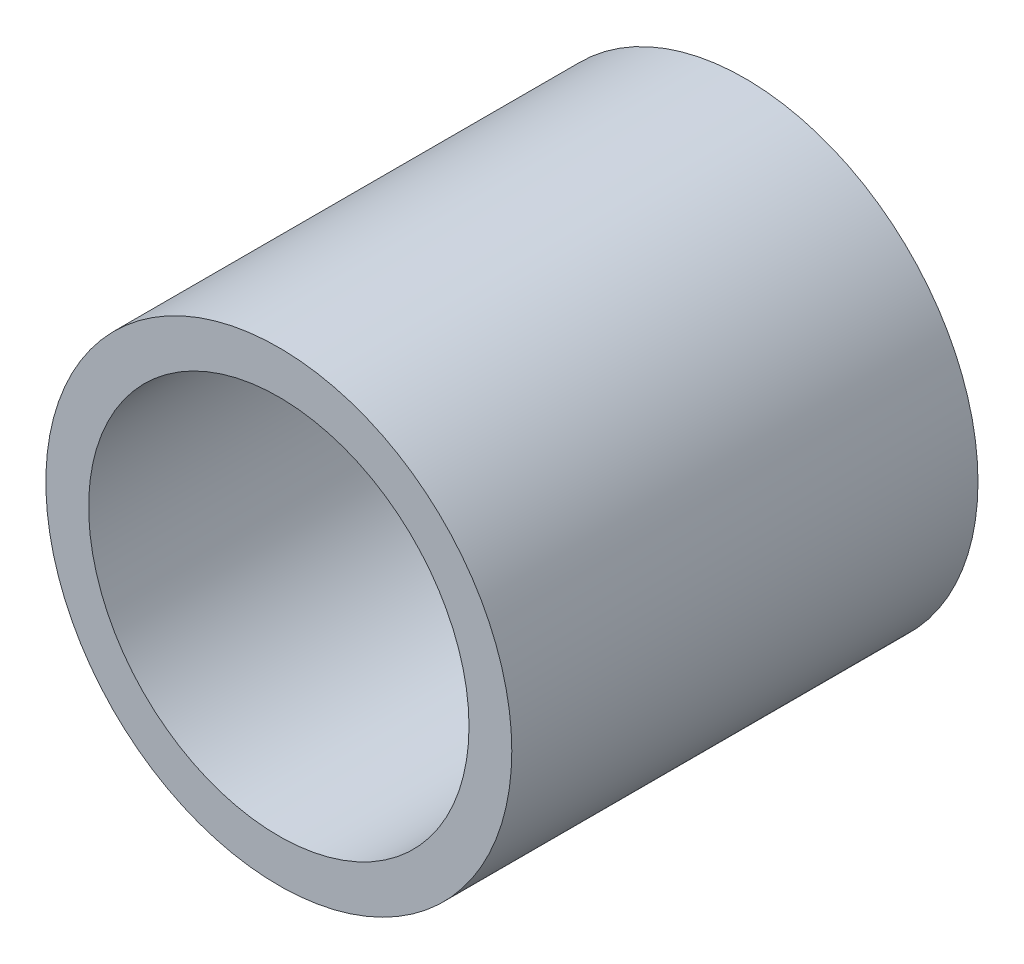
from build123d import *

# Parameters (mm, degrees)
SKIZZE1_R                       = 5.0225
SKIZZE1_R_2                     = 4.1
AUFSATZ_LINEAR_AUSTRAGEN1_DEPTH = 10.05


with BuildPart() as part:
    # Skizze1 → Aufsatz-Linear austragen1 (new body)
    with BuildSketch(Plane.XY):
        Circle(SKIZZE1_R)
        Circle(SKIZZE1_R_2, mode=Mode.SUBTRACT)
    extrude(amount=AUFSATZ_LINEAR_AUSTRAGEN1_DEPTH)


solid = part.part
